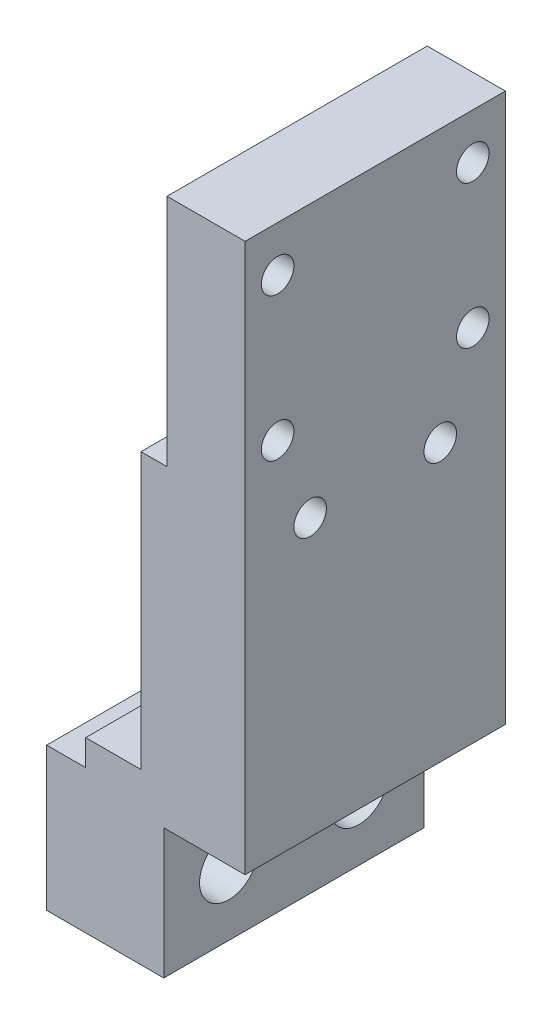
from build123d import *

# Parameters (mm, degrees)
EXTRUDE_1_DEPTH              = 20
HOLE_WIZARD_M3_1_D           = 2.5
HOLE_WIZARD_M3_1_DEPTH       = 9.5
HOLE_WIZARD_M3_1_TIP         = 0.751075774
HOLE_WIZARD_M4_1_D           = 4.5
HOLE_WIZARD_M4_1_DEPTH       = 9.5
HOLE_WIZARD_M4_1_CBORE_D     = 8
HOLE_WIZARD_M4_1_CBORE_DEPTH = 4.4
HOLE_WIZARD_M4_1_TIP         = 1.351936393


with BuildPart() as part:
    # 草图1 → 凸台-拉伸1 (new body)
    with BuildSketch(Plane.XY):
        Polygon((-6, 13), (-1.75, 13), (-1.75, 34.16), (0.25, 34.16), (0.25, 52.16), (6.25, 52.16), (6.25, 10), (0, 10), (0, 0), (-9, 0), (-9, 11), (-6, 11), align=None)
    extrude(amount=EXTRUDE_1_DEPTH)

    # M3 螺纹孔1
    with Locations(Plane(origin=(6.25, 0, 0), x_dir=(0, 0, -1), z_dir=(1, 0, 0))):
        with Locations((-2.5, 48.66), (-2.5, 37.66), (-5, 31.26), (-15, 31.26), (-17.5, 37.66), (-17.5, 48.66)):
            Hole(HOLE_WIZARD_M3_1_D / 2, depth=HOLE_WIZARD_M3_1_DEPTH)
            with Locations((0, 0, -(HOLE_WIZARD_M3_1_DEPTH + HOLE_WIZARD_M3_1_TIP / 2))):  # 118° drill point
                Cone(0, HOLE_WIZARD_M3_1_D / 2, HOLE_WIZARD_M3_1_TIP, mode=Mode.SUBTRACT)

    # M4 六角凹头螺钉的柱形沉头孔1
    with Locations(Plane.ZY.offset(9)):
        with Locations((5, 4.96), (15, 4.96)):
            CounterBoreHole(HOLE_WIZARD_M4_1_D / 2, HOLE_WIZARD_M4_1_CBORE_D / 2, HOLE_WIZARD_M4_1_CBORE_DEPTH, depth=HOLE_WIZARD_M4_1_DEPTH)
            with Locations((0, 0, -(HOLE_WIZARD_M4_1_DEPTH + HOLE_WIZARD_M4_1_TIP / 2))):  # 118° drill point
                Cone(0, HOLE_WIZARD_M4_1_D / 2, HOLE_WIZARD_M4_1_TIP, mode=Mode.SUBTRACT)


solid = part.part
